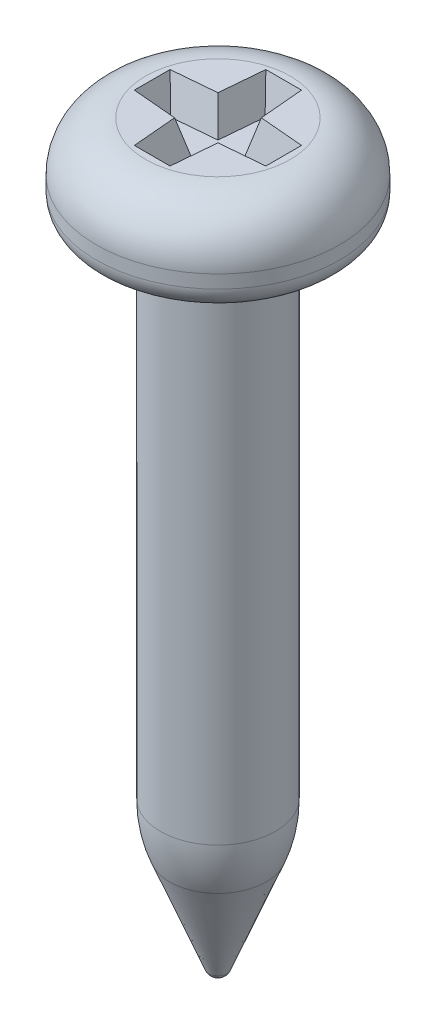
from build123d import *

# Parameters (mm, degrees)
CUT_EXTRUDE1_DEPTH = 0.5
CUT_EXTRUDE1_TAPER = 15


with BuildPart() as part:
    # Sketch1 → Revolve1 (revolve)
    with BuildSketch(Plane.XY):
        with BuildLine():
            Line((0.875, -8.964405423), (0.875, -1.45))
            ThreePointArc((0.875, -1.45), (0.918933983, -1.343933983), (1.025, -1.3))
            Line((1.025, -1.3), (1.5, -1.3))
            ThreePointArc((1.5, -1.3), (1.747487373, -1.197487373), (1.85, -0.95))
            Line((1.85, -0.95), (1.85, -0.75))
            ThreePointArc((1.85, -0.75), (1.630330086, -0.219669914), (1.1, 0))
            Line((1.1, 0), (0, 0))
            Line((0, 0), (0, -11.3))
            ThreePointArc((0, -11.3), (0.084334338, -11.274047247), (0.139485899, -11.205169593))
            Line((0.139485899, -11.205169593), (0.734811985, -9.7))
            ThreePointArc((0.734811985, -9.7), (0.839640421, -9.338822324), (0.875, -8.964405423))
        make_face()
    revolve(axis=Axis((0, 0, 0), (0, -1, 0)))

    # Sketch2 → Cut-Extrude1 (cut)
    with BuildSketch(Plane(origin=(0, 0, 0), x_dir=(1, 0, 0), z_dir=(0, 1, 0))):
        Polygon((-0.271382595, 1), (-0.33, 0.33), (-1, 0.271382595), (-1, -0.271382595), (-0.33, -0.33), (-0.271382595, -1), (0.271382595, -1), (0.33, -0.33), (1, -0.271382595), (1, 0.271382595), (0.33, 0.33), (0.271382595, 1), align=None)
    extrude(amount=-CUT_EXTRUDE1_DEPTH, taper=CUT_EXTRUDE1_TAPER, mode=Mode.SUBTRACT)


solid = part.part
